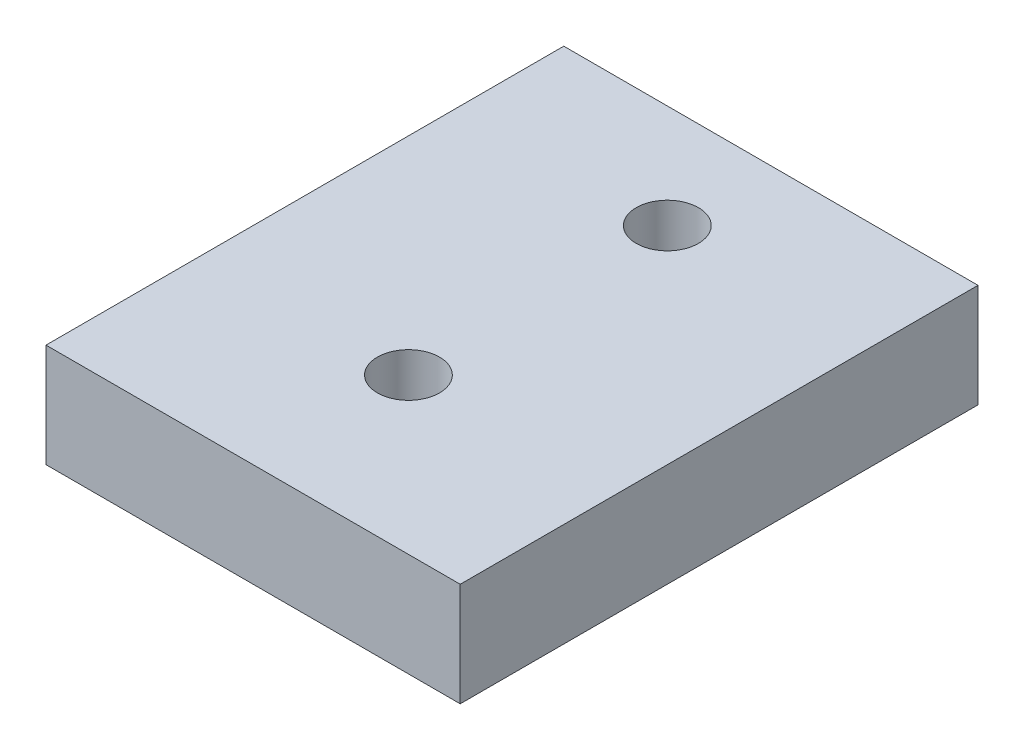
from build123d import *

# Parameters (mm, degrees)
SKETCH1_W           = 40
SKETCH1_H           = 50
SKETCH1_R           = 3
BOSS_EXTRUDE1_DEPTH = 10


with BuildPart() as part:
    # Sketch1 → Boss-Extrude1 (new body)
    with BuildSketch(Plane(origin=(0, 0, 0), x_dir=(1, 0, 0), z_dir=(0, 1, 0))):
        with Locations((20, 25)):
            Rectangle(SKETCH1_W, SKETCH1_H)
        with Locations((20, 15)):
            Circle(SKETCH1_R, mode=Mode.SUBTRACT)
        with Locations((20, 40)):
            Circle(SKETCH1_R, mode=Mode.SUBTRACT)
    extrude(amount=BOSS_EXTRUDE1_DEPTH)


solid = part.part
